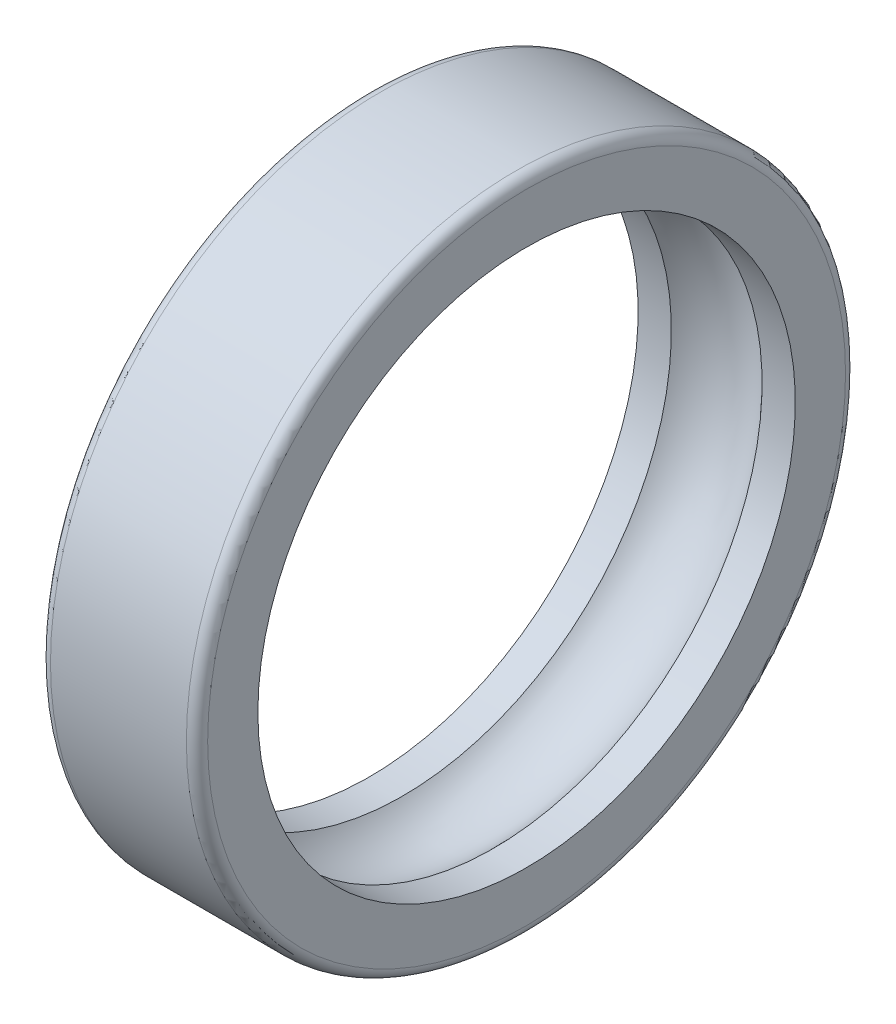
from build123d import *

# Parameters (mm, degrees)
FILLET1_R = 2.1


with BuildPart() as part:
    # Sketch1 → Revolve1 (revolve)
    with BuildSketch(Plane.XY):
        with BuildLine():
            Line((-15.5, 53), (-8.94427191, 53))
            ThreePointArc((-8.94427191, 53), (0, 57), (8.94427191, 53))
            Line((8.94427191, 53), (15.5, 53))
            Line((15.5, 53), (15.5, 65))
            Line((15.5, 65), (-15.5, 65))
            Line((-15.5, 65), (-15.5, 53))
        make_face()
    revolve(axis=Axis((-47.791666667, 0, 0), (1, 0, 0)))

    # Fillet1
    fillet1_edges = [part.edges().sort_by_distance(p)[0] for p in [
        (15.5, -65, 0),
        (-15.5, -65, 0),
    ]]
    fillet(fillet1_edges, radius=FILLET1_R)


solid = part.part
